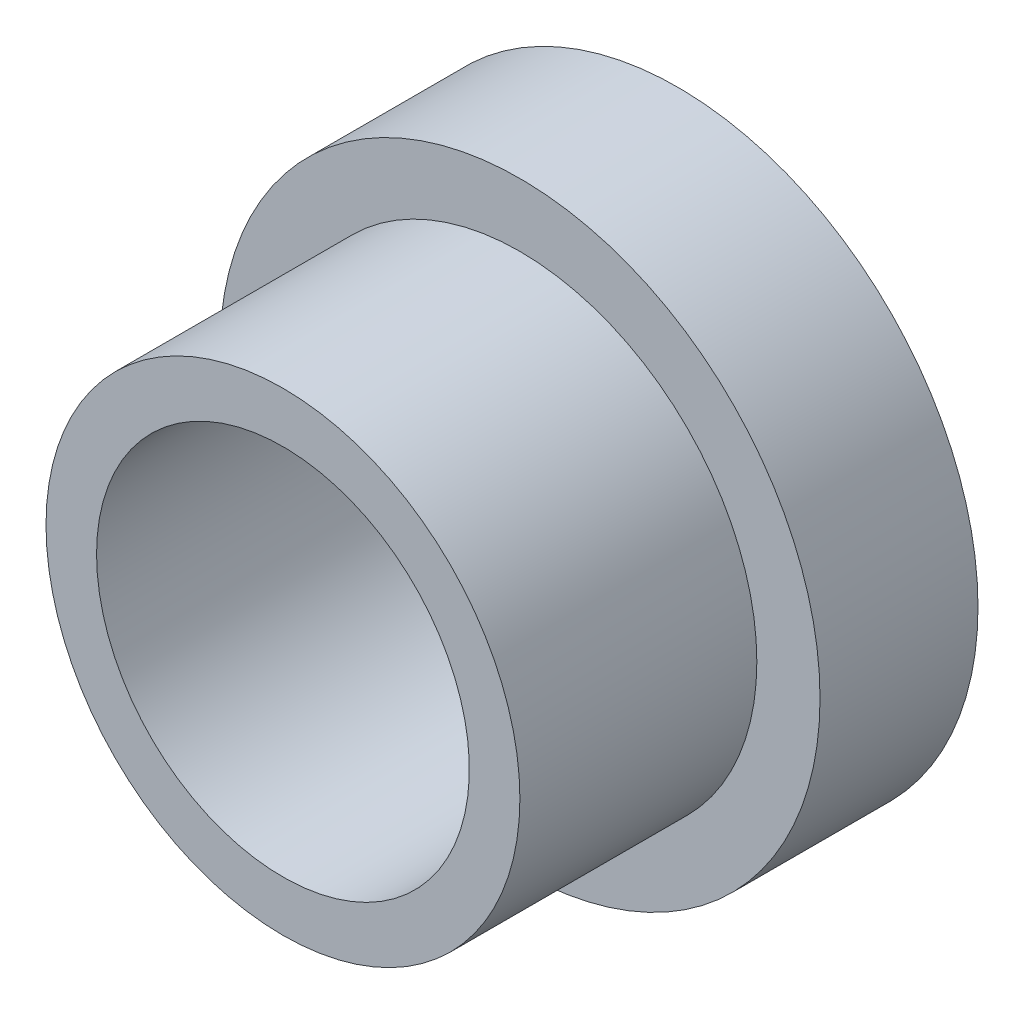
from build123d import *

# Parameters (mm, degrees)
SKETCH1_R           = 12.065
BOSS_EXTRUDE1_DEPTH = 6.35
SKETCH2_R           = 9.525
BOSS_EXTRUDE2_DEPTH = 9.525
SKETCH3_R           = 7.493
CUT_EXTRUDE1_DEPTH  = 16.875
SKETCH4_R           = 1.7272
CUT_EXTRUDE2_DEPTH  = 13.065


with BuildPart() as part:
    # Sketch1 → Boss-Extrude1 (new body)
    with BuildSketch(Plane.XY):
        Circle(SKETCH1_R)
    extrude(amount=BOSS_EXTRUDE1_DEPTH)

    # Sketch2 → Boss-Extrude2 (add)
    with BuildSketch(Plane.XY.offset(6.35)):
        Circle(SKETCH2_R)
    extrude(amount=BOSS_EXTRUDE2_DEPTH)

    # Sketch3 → Cut-Extrude1 (cut, through all)
    with BuildSketch(Plane(origin=(0, 0, 0), x_dir=(-1, 0, 0), z_dir=(0, 0, -1))):
        Circle(SKETCH3_R)
    extrude(amount=-CUT_EXTRUDE1_DEPTH, mode=Mode.SUBTRACT)

    # Sketch4 → Cut-Extrude2 (cut, through all)
    with BuildSketch(Plane(origin=(0, 0, 0), x_dir=(0, 0, -1), z_dir=(1, 0, 0))):
        with Locations((-3.175, 0)):
            Circle(SKETCH4_R)
    extrude(amount=-CUT_EXTRUDE2_DEPTH, mode=Mode.SUBTRACT)


solid = part.part
